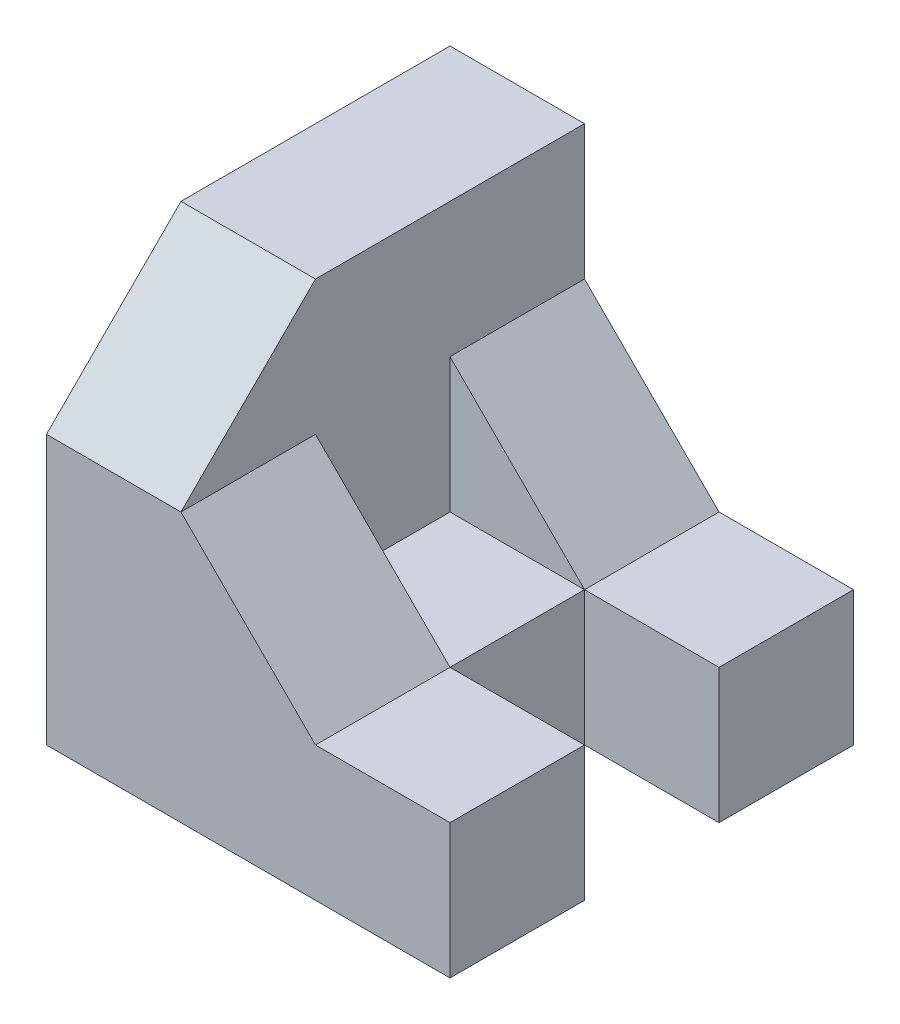
from build123d import *

# Parameters (mm, degrees)
SALIENTE_EXTRUIR1_DEPTH = 60
CORTAR_EXTRUIR1_DEPTH   = 20
CROQUIS6_W              = 20
CROQUIS6_H              = 20
CORTAR_EXTRUIR3_DEPTH   = 10


with BuildPart() as part:
    # Croquis3 → Saliente-Extruir1 (new body)
    with BuildSketch(Plane.XY):
        Polygon((0, 0), (60, 0), (60, 20), (40, 20), (20, 40), (20, 60), (0, 60), align=None)
    extrude(amount=-SALIENTE_EXTRUIR1_DEPTH)

    # Croquis4 → Cortar-Extruir1 (cut)
    with BuildSketch(Plane(origin=(20, 0, 0), x_dir=(0, 0, -1), z_dir=(1, 0, 0))):
        Polygon((0, 40), (20, 60), (0, 60), align=None)
    extrude(amount=-CORTAR_EXTRUIR1_DEPTH, mode=Mode.SUBTRACT)

    # Croquis6 → Cortar-Extruir3 (cut, symmetric)
    with BuildSketch(Plane.XY.offset(-30)):
        Polygon((20, 40), (20, 20), (40, 20), align=None)
        with Locations((50, 10)):
            Rectangle(CROQUIS6_W, CROQUIS6_H)
    extrude(amount=CORTAR_EXTRUIR3_DEPTH, both=True, mode=Mode.SUBTRACT)


solid = part.part
